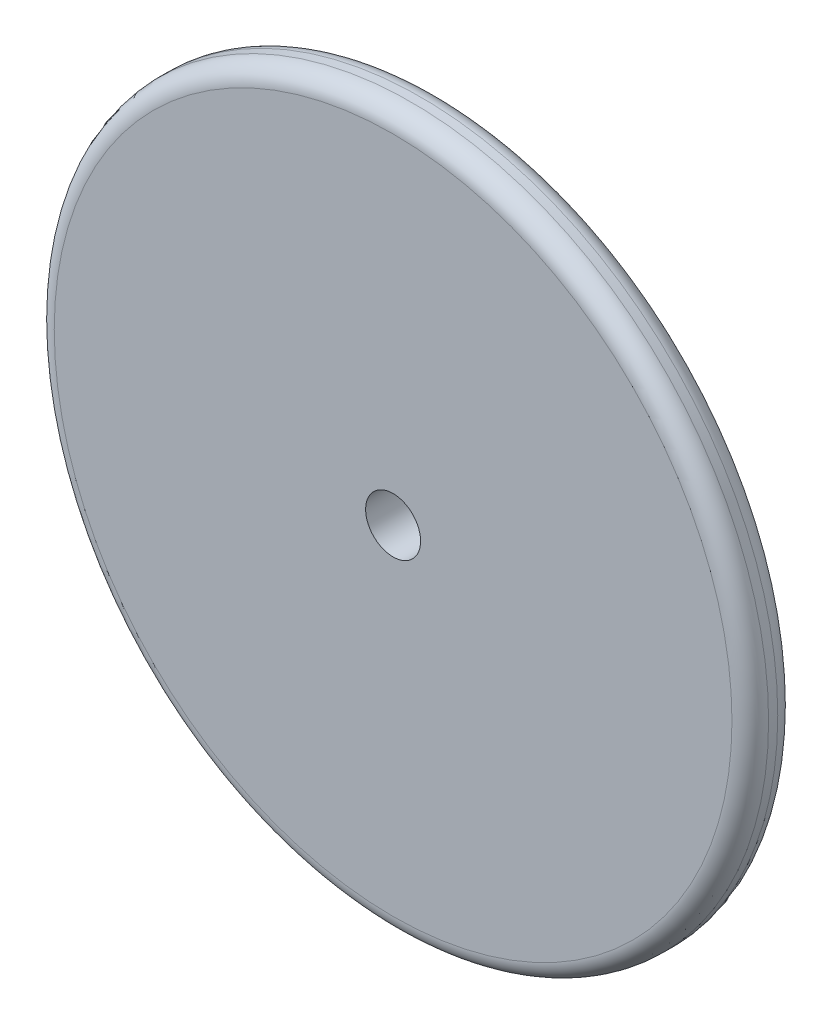
from build123d import *

# Parameters (mm, degrees)
SKETCH_1_R      = 39
SKETCH_1_R_2    = 3
EXTRUDE_1_DEPTH = 5
FILLET_1_R      = 2


with BuildPart() as part:
    # 草图1 → 凸台-拉伸1 (new body)
    with BuildSketch(Plane.XY):
        Circle(SKETCH_1_R)
        Circle(SKETCH_1_R_2, mode=Mode.SUBTRACT)
    extrude(amount=EXTRUDE_1_DEPTH)

    # 圆角1
    fillet_1_edges = [part.edges().sort_by_distance(p)[0] for p in [
        (-39, 0, 0),
        (-39, 0, 5),
    ]]
    fillet(fillet_1_edges, radius=FILLET_1_R)


solid = part.part
